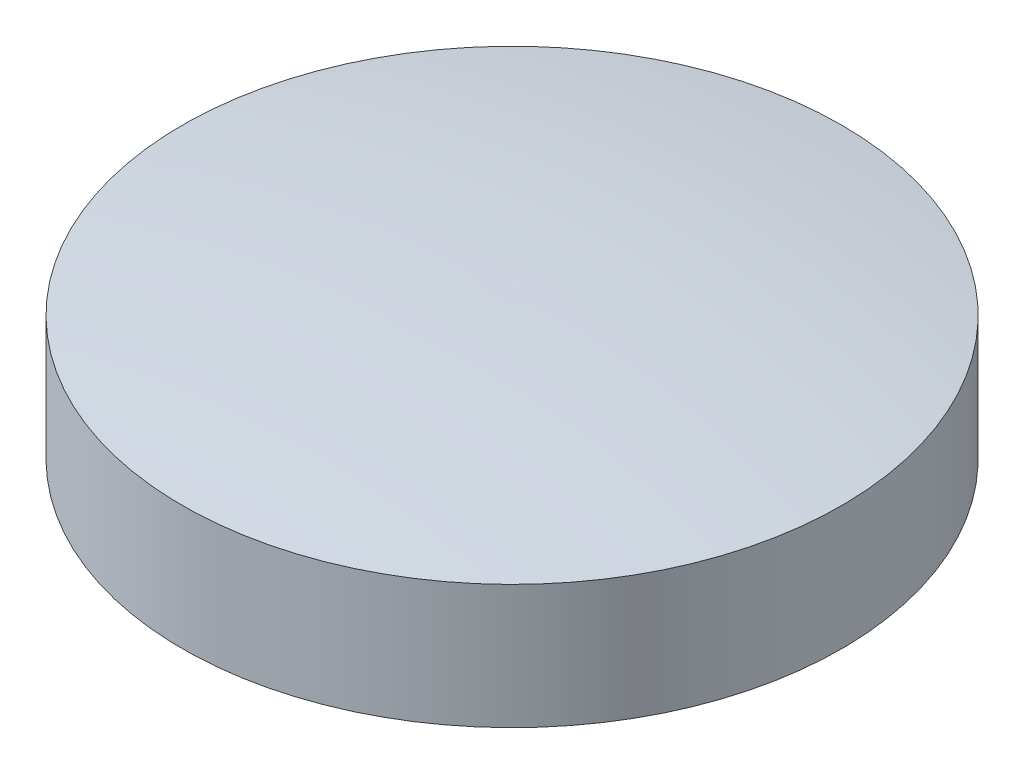
from build123d import *


with BuildPart() as part:
    # Skizze3 → Rotation1 (revolve)
    with BuildSketch(Plane(origin=(0, 0, 0), x_dir=(0, 0, -1), z_dir=(1, 0, 0))):
        with BuildLine():
            Line((0, 0), (25.5, 0))
            Line((25.5, 0), (25.5, 9.6))
            ThreePointArc((25.5, 9.6), (12.789095065, 11.078281144), (0, 11.515850372))
            Line((0, 11.515850372), (0, 0))
        make_face()
    revolve(axis=Axis((0, 0, 0), (0, 1, 0)))


solid = part.part
